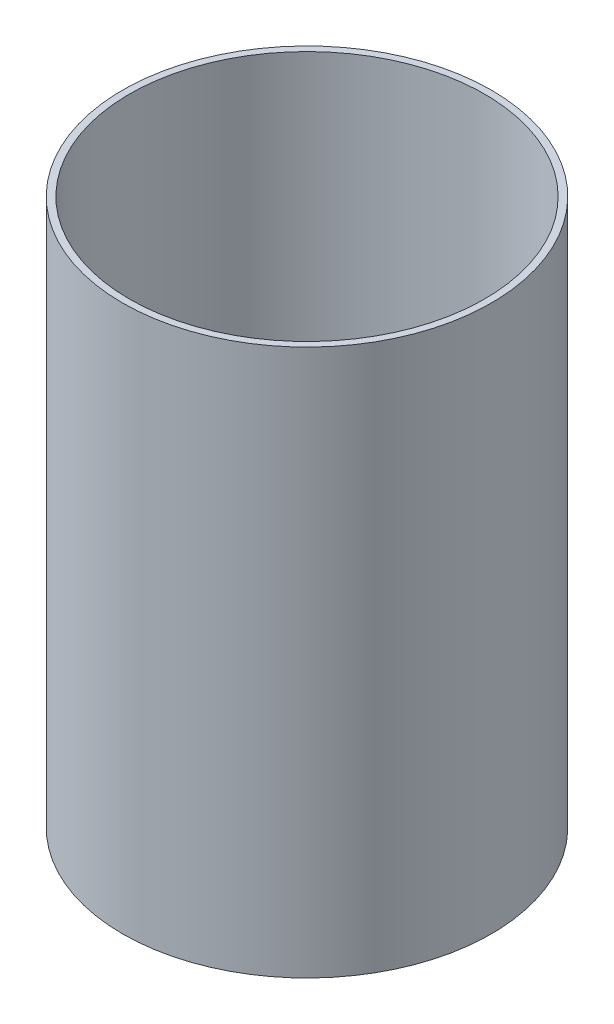
from build123d import *

# Parameters (mm, degrees)
SKETCH1_R           = 68.58
SKETCH1_R_2         = 66.04
BOSS_EXTRUDE1_DEPTH = 203.2


with BuildPart() as part:
    # Sketch1 → Boss-Extrude1 (new body)
    with BuildSketch(Plane(origin=(0, 0, 0), x_dir=(1, 0, 0), z_dir=(0, 1, 0))):
        Circle(SKETCH1_R)
        Circle(SKETCH1_R_2, mode=Mode.SUBTRACT)
    extrude(amount=BOSS_EXTRUDE1_DEPTH)


solid = part.part
